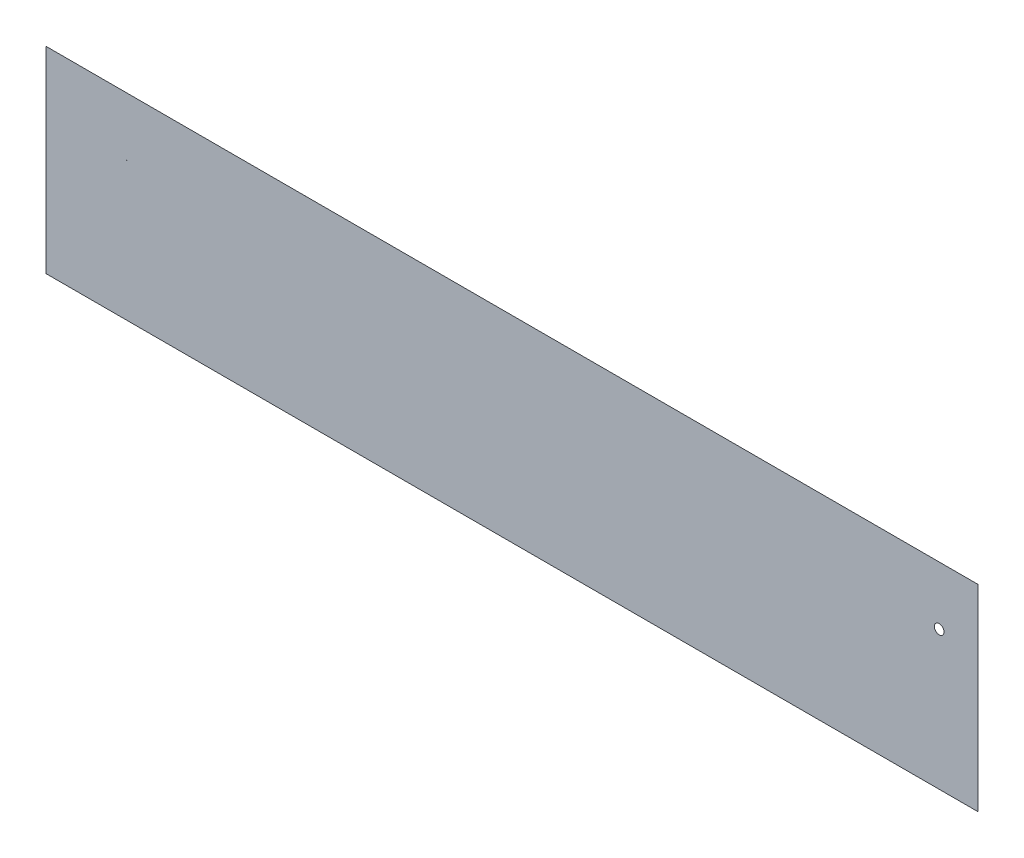
from build123d import *

# Parameters (mm, degrees)
SKETCH1_W           = 609.6
SKETCH1_H           = 128.778
SKETCH1_R           = 0.174798991
SKETCH1_R_2         = 3.175
BOSS_EXTRUDE1_DEPTH = 0.000100076


with BuildPart() as part:
    # Sketch1 → Boss-Extrude1 (new body)
    with BuildSketch(Plane.XY):
        with Locations((304.8, 64.389)):
            Rectangle(SKETCH1_W, SKETCH1_H)
        with Locations((52.974692136, 90.678)):
            Circle(SKETCH1_R, mode=Mode.SUBTRACT)
        with Locations((584.2, 90.678)):
            Circle(SKETCH1_R_2, mode=Mode.SUBTRACT)
    extrude(amount=BOSS_EXTRUDE1_DEPTH)


solid = part.part
